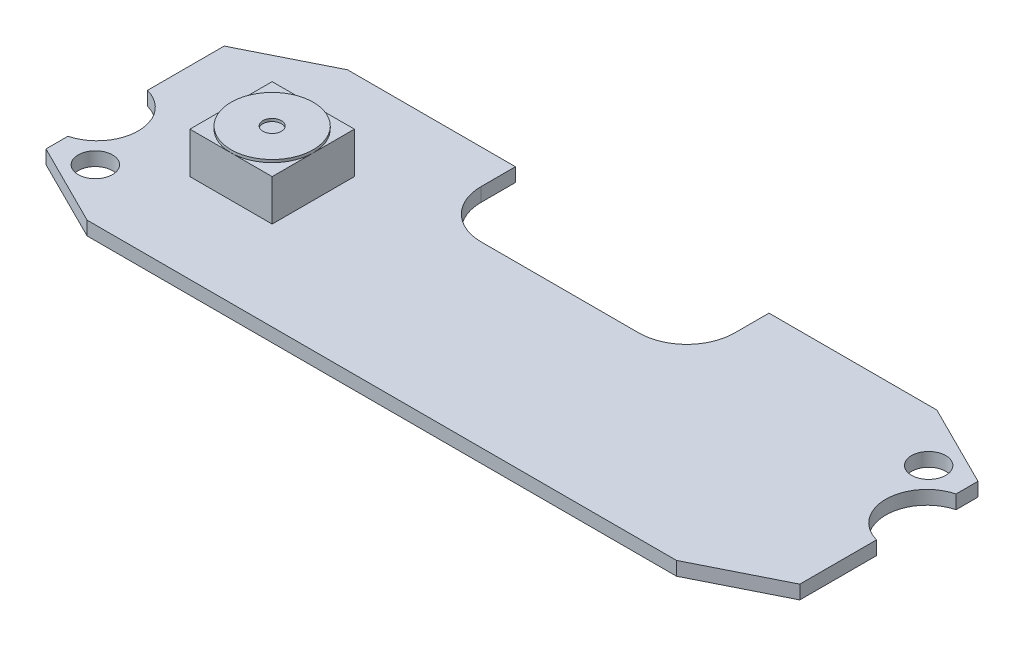
from build123d import *

# Parameters (mm, degrees)
SKETCH_1_R      = 1.25
EXTRUDE_1_DEPTH = 1
SKETCH_1_3_W    = 6
SKETCH_1_3_H    = 6
EXTRUDE_2_DEPTH = 4
EXTRUDE_START   = 4
SKETCH_1_4_R    = 0.675
EXTRUDE_5_DEPTH = 0.2


with BuildPart() as part:
    # 草圖1 → 填料-伸長1 (new body)
    with BuildSketch(Plane(origin=(0, 0, 0), x_dir=(1, 0, 0), z_dir=(0, 1, 0))):
        with BuildLine():
            Line((-27.5, -6.5), (-21.5, -9.5))
            Line((-21.5, -9.5), (21.5, -9.5))
            Line((21.5, -9.5), (27.5, -6.5))
            Line((27.5, -6.5), (27.5, -0.9))
            ThreePointArc((27.5, -0.9), (25.268114575, 2), (27.5, 4.9))
            Line((27.5, 4.9), (27.5, 6.5))
            Line((27.5, 6.5), (21.5, 9.5))
            Line((21.5, 9.5), (9.25, 9.5))
            Line((9.25, 9.5), (9.25, 7))
            ThreePointArc((9.25, 7), (8.224873734, 4.525126266), (5.75, 3.5))
            Line((5.75, 3.5), (-5.75, 3.5))
            ThreePointArc((-5.75, 3.5), (-8.224873734, 4.525126266), (-9.25, 7))
            Line((-9.25, 7), (-9.25, 9.5))
            Line((-9.25, 9.5), (-21.5, 9.5))
            Line((-21.5, 9.5), (-27.5, 6.5))
            Line((-27.5, 6.5), (-27.5, 0.9))
            ThreePointArc((-27.5, 0.9), (-25.268114575, -2), (-27.5, -4.9))
            Line((-27.5, -4.9), (-27.5, -6.5))
        make_face()
        with Locations((-24.699999952, -5.700000209)):
            Circle(SKETCH_1_R, mode=Mode.SUBTRACT)
        with Locations((24.7, 5.7)):
            Circle(SKETCH_1_R, mode=Mode.SUBTRACT)
    extrude(amount=EXTRUDE_1_DEPTH)

    # 草圖1<3> → 填料-伸長2 (add)
    with BuildSketch(Plane(origin=(0, 0, 0), x_dir=(1, 0, 0), z_dir=(0, 1, 0))):
        with Locations((-17.5, 0)):
            Rectangle(SKETCH_1_3_W, SKETCH_1_3_H)
    extrude(amount=EXTRUDE_2_DEPTH)

    # 草圖1<4> → 填料-伸長5 (add)
    with BuildSketch(Plane(origin=(0, 0, 0), x_dir=(1, 0, 0), z_dir=(0, 1, 0)).offset(EXTRUDE_START)):
        with BuildLine():
            ThreePointArc((-20.5, 0), (-19.621320344, -2.121320344), (-17.5, -3))
            ThreePointArc((-17.5, -3), (-15.378679656, -2.121320344), (-14.5, 0))
            ThreePointArc((-14.5, 0), (-15.378679656, 2.121320344), (-17.5, 3))
            ThreePointArc((-17.5, 3), (-19.621320344, 2.121320344), (-20.5, 0))
        make_face()
        with Locations((-17.5, 0)):
            Circle(SKETCH_1_4_R, mode=Mode.SUBTRACT)
    extrude(amount=EXTRUDE_5_DEPTH)


solid = part.part
